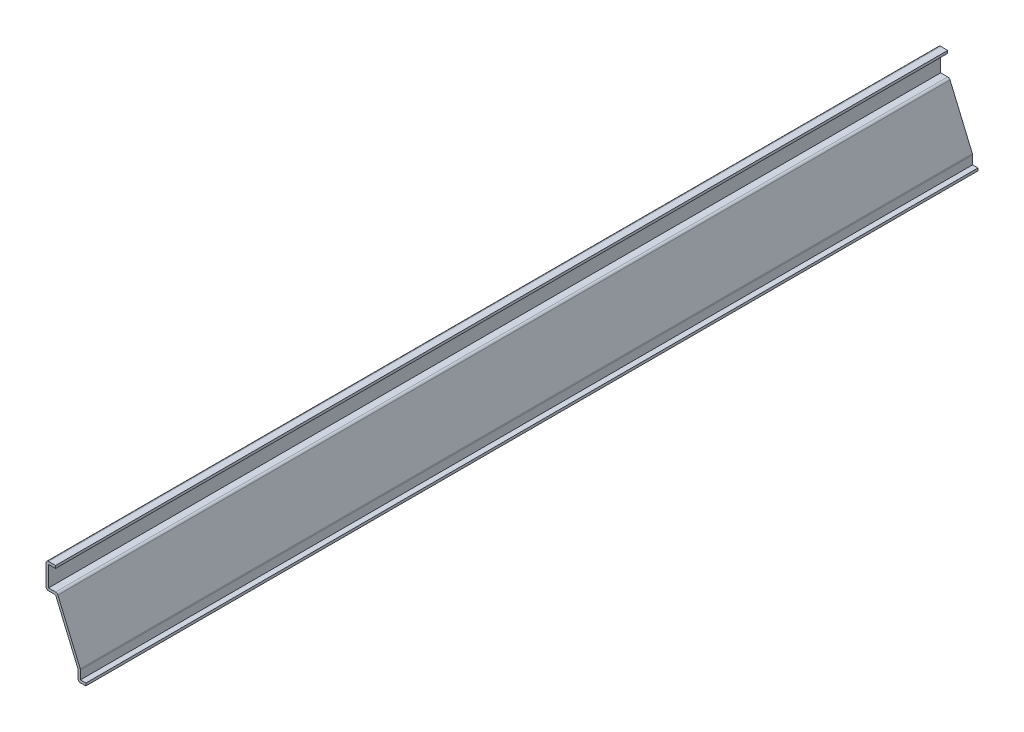
from build123d import *

# Parameters (mm, degrees)
EXTRUDE_THIN1_DEPTH = 444.5
FILLET1_R           = 1.27


with BuildPart() as part:
    # Sketch1 → Extrude-Thin1 (new body)
    with BuildSketch(Plane.XY):
        Polygon((0, 0), (-3.96875, 0), (-3.96875, 5.55625), (-15.08125, 31.75), (-19.84375, 31.75), (-19.84375, 44.45), (-15.08125, 44.45), (-15.08125, 43.18), (-18.57375, 43.18), (-18.57375, 33.02), (-14.240475492, 33.02), (-2.69875, 5.814504197), (-2.69875, 1.27), (0, 1.27), align=None)
    extrude(amount=-EXTRUDE_THIN1_DEPTH)

    # Fillet1
    fillet1_edges = [part.edges().sort_by_distance(p)[0] for p in [
        (-14.240475492, 33.02, -222.25),
        (-2.69875, 5.814504197, -222.25),
        (-3.96875, 0, -222.25),
        (-19.84375, 31.75, -222.25),
        (-19.84375, 44.45, -222.25),
    ]]
    fillet(fillet1_edges, radius=FILLET1_R)


solid = part.part
